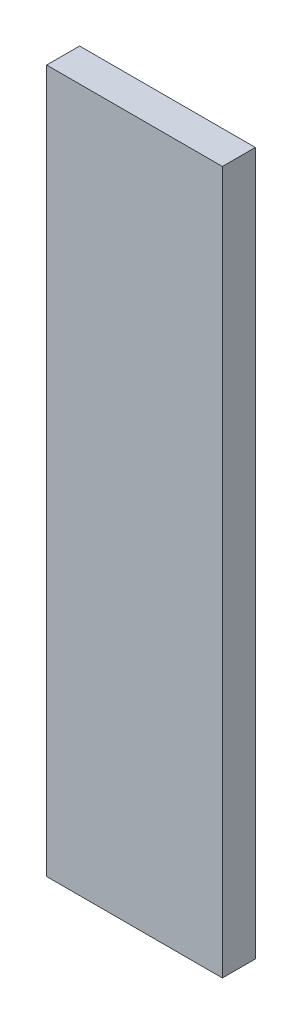
from build123d import *

# Parameters (mm, degrees)
SKETCH1_W           = 25.4
SKETCH1_H           = 101.6
BOSS_EXTRUDE1_DEPTH = 4.7625


with BuildPart() as part:
    # Sketch1 → Boss-Extrude1 (new body)
    with BuildSketch(Plane.XY):
        Rectangle(SKETCH1_W, SKETCH1_H)
    extrude(amount=BOSS_EXTRUDE1_DEPTH)


solid = part.part
